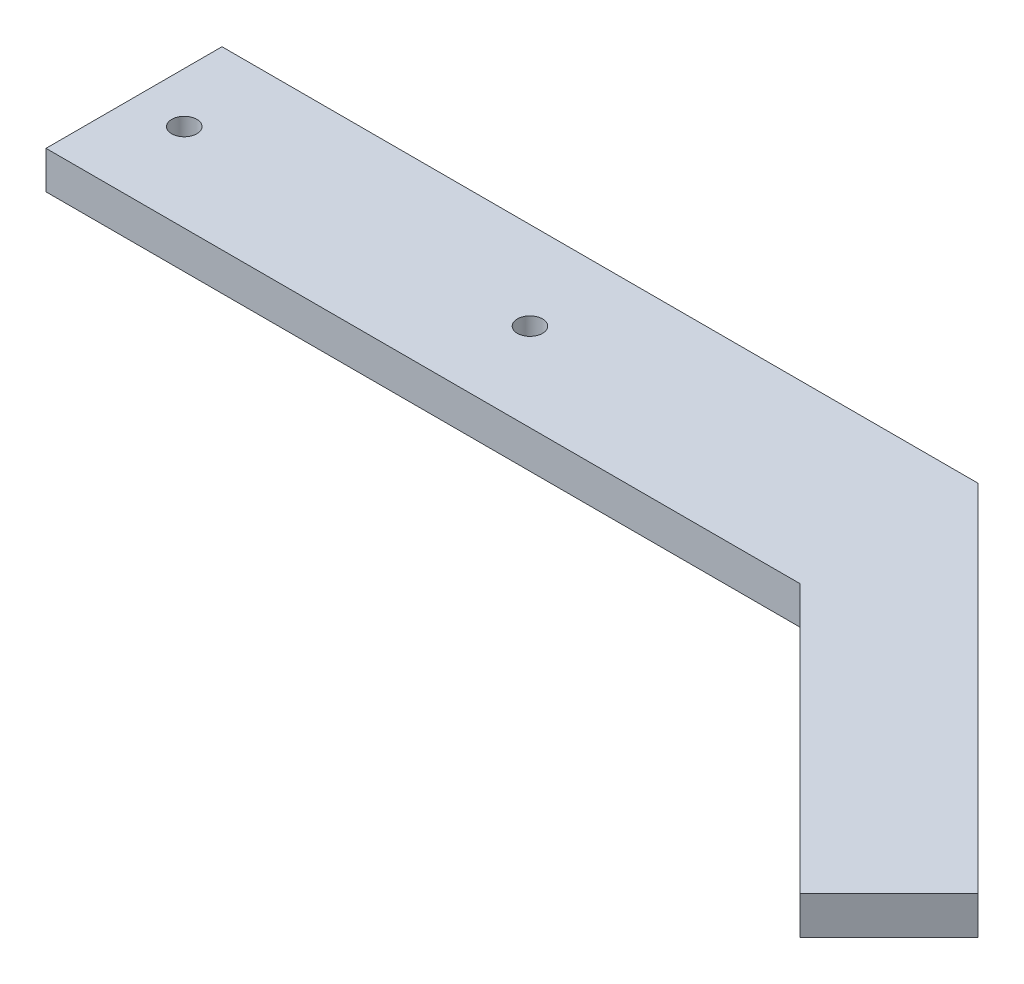
from build123d import *

# Parameters (mm, degrees)
BOSS_EXTRUDE1_DEPTH = 3
SKETCH2_R           = 1
CUT_EXTRUDE1_DEPTH  = 3


with BuildPart() as part:
    # Sketch1 → Boss-Extrude1 (new body)
    with BuildSketch(Plane(origin=(0, 0, 0), x_dir=(1, 0, 0), z_dir=(0, 1, 0))):
        Polygon((81.355339059, -21.355339059), (60, 0), (0, 0), (0, 14), (60.142135624, 14), (88.426406871, -14.284271247), align=None)
    extrude(amount=BOSS_EXTRUDE1_DEPTH)

    # Sketch2 → Cut-Extrude1 (cut)
    with BuildSketch(Plane(origin=(0, 3, 0), x_dir=(1, 0, 0), z_dir=(0, 1, 0))):
        with Locations((4, 7)):
            Circle(SKETCH2_R)
        with Locations((31.5, 7)):
            Circle(SKETCH2_R)
    extrude(amount=-CUT_EXTRUDE1_DEPTH, mode=Mode.SUBTRACT)


solid = part.part
